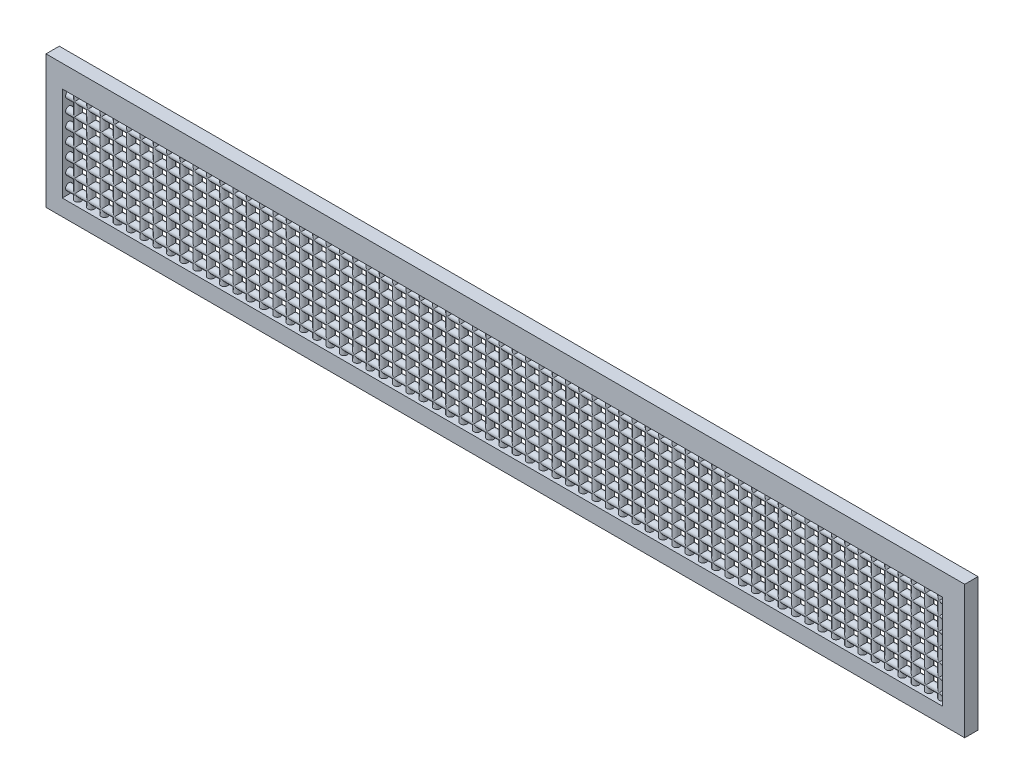
from build123d import *

# Parameters (mm, degrees)
SKETCH2_W           = 34.54
SKETCH2_H           = 5
BOSS_EXTRUDE2_DEPTH = 0.5
SKETCH5_W           = 33.091084896
SKETCH5_H           = 3.55189634
CUT_EXTRUDE1_DEPTH  = 1
SKETCH7_R           = 0.125
BOSS_EXTRUDE4_DEPTH = 3.55
LPATTERN2_COUNT     = 66
LPATTERN2_PITCH     = 0.5
SKETCH8_R           = 0.125
BOSS_EXTRUDE5_DEPTH = 33.1
LPATTERN3_COUNT     = 7
LPATTERN3_PITCH     = 0.5


with BuildPart() as part:
    # Sketch2 → Boss-Extrude2 (new body)
    with BuildSketch(Plane.XY):
        with Locations((-25.198790507, 33.651032836)):
            Rectangle(SKETCH2_W, SKETCH2_H)
    extrude(amount=BOSS_EXTRUDE2_DEPTH)

    # Sketch5 → Cut-Extrude1 (cut)
    with BuildSketch(Plane.XY.offset(0.5)):
        with Locations((-25.31119229, 33.538631053)):
            Rectangle(SKETCH5_W, SKETCH5_H)
    extrude(amount=-CUT_EXTRUDE1_DEPTH, mode=Mode.SUBTRACT)

    # Sketch7 → Boss-Extrude4 (add)
    with BuildSketch(Plane(origin=(0, 31.762682883, 0), x_dir=(1, 0, 0), z_dir=(0, 1, 0))):
        with Locations((-9.015649842, -0.25)):
            Circle(SKETCH7_R)
    boss_extrude4 = extrude(amount=BOSS_EXTRUDE4_DEPTH)

    # LPattern2: Boss-Extrude4 ×66
    with Locations(*[(-i * LPATTERN2_PITCH, 0, 0) for i in range(1, LPATTERN2_COUNT)]):
        add(boss_extrude4)

    # Sketch8 → Boss-Extrude5 (add)
    with BuildSketch(Plane.ZY.offset(8.765649842)):
        with Locations((0.25, 32.012682883)):
            Circle(SKETCH8_R)
    boss_extrude5 = extrude(amount=BOSS_EXTRUDE5_DEPTH)

    # LPattern3: Boss-Extrude5 ×7
    with Locations(*[(0, i * LPATTERN3_PITCH, 0) for i in range(1, LPATTERN3_COUNT)]):
        add(boss_extrude5)


solid = part.part
